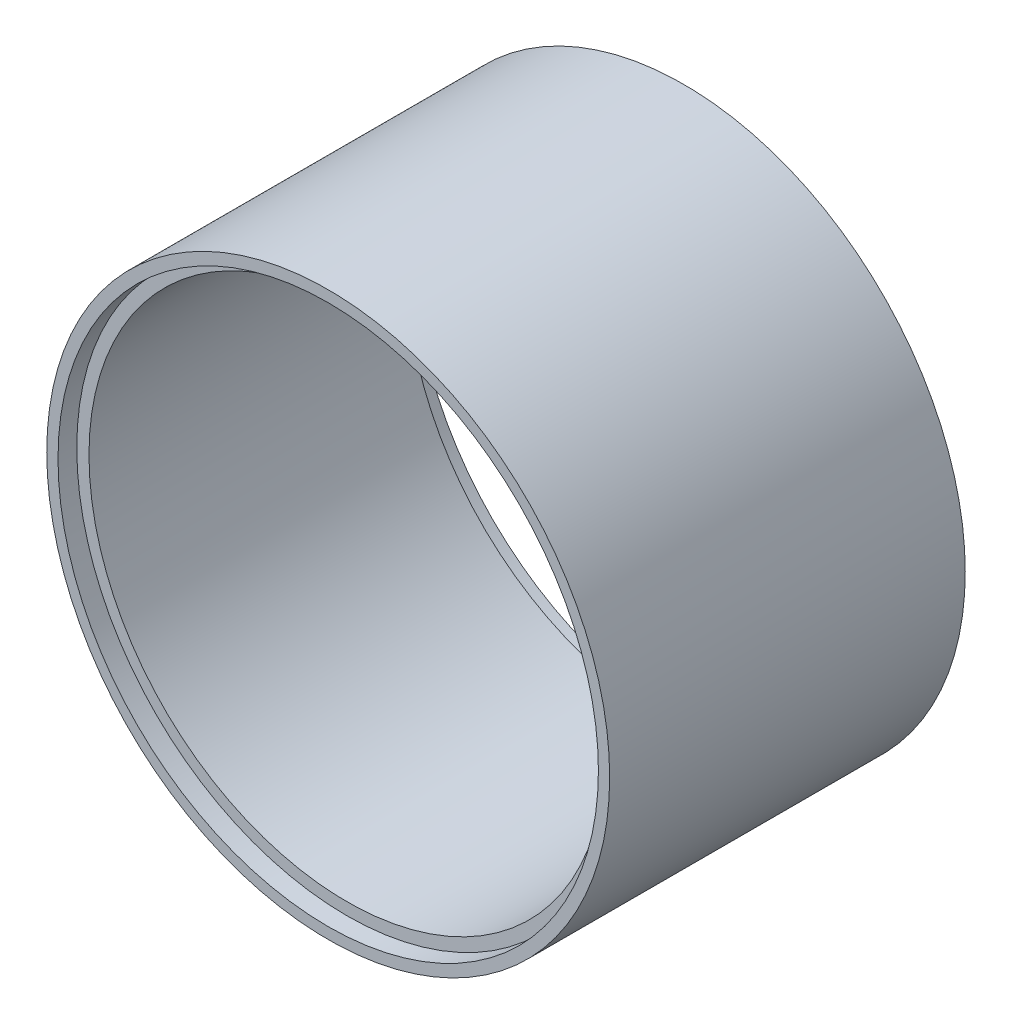
from build123d import *

# Parameters (mm, degrees)
BOSS_EXTRUDE1_START = -2
SKETCH1_R           = 30
SKETCH1_R_2         = 27.5
BOSS_EXTRUDE1_DEPTH = 37.9
SKETCH2_R           = 28.8
CUT_EXTRUDE1_DEPTH  = 2
SKETCH3_R           = 28.8
CUT_EXTRUDE2_DEPTH  = 2
SKETCH5_R           = 26
CUT_EXTRUDE3_DEPTH  = 38.9


with BuildPart() as part:
    # Sketch1 → Boss-Extrude1 (new body)
    with BuildSketch(Plane.XY.offset(BOSS_EXTRUDE1_START)):
        with Locations((0, -108.5)):
            Circle(SKETCH1_R)
        with Locations((0, -108.5)):
            Circle(SKETCH1_R_2, mode=Mode.SUBTRACT)
    extrude(amount=-BOSS_EXTRUDE1_DEPTH)

    # Sketch2 → Cut-Extrude1 (cut)
    with BuildSketch(Plane.XY.offset(-2)):
        with Locations((0, -108.5)):
            Circle(SKETCH2_R)
    extrude(amount=-CUT_EXTRUDE1_DEPTH, mode=Mode.SUBTRACT)

    # Sketch3 → Cut-Extrude2 (cut)
    with BuildSketch(Plane(origin=(0, 0, -39.9), x_dir=(-1, 0, 0), z_dir=(0, 0, -1))):
        with Locations((0, -108.5)):
            Circle(SKETCH3_R)
    extrude(amount=-CUT_EXTRUDE2_DEPTH, mode=Mode.SUBTRACT)

    # Sketch4 → Revolve1 (revolve)
    with BuildSketch(Plane(origin=(0, 0, 0), x_dir=(0, 0, -1), z_dir=(1, 0, 0))):
        Polygon((20.95, -79.75), (20.95, -83.75), (18.45, -83.75), align=None)
    revolve(axis=Axis((0, -79.75, -20.95), (0, -1, 0)))

    # Sketch5 → Cut-Extrude3 (cut, through all)
    with BuildSketch(Plane.XY.offset(-2)):
        with Locations((0, -108.5)):
            Circle(SKETCH5_R)
    extrude(amount=-CUT_EXTRUDE3_DEPTH, mode=Mode.SUBTRACT)


solid = part.part
